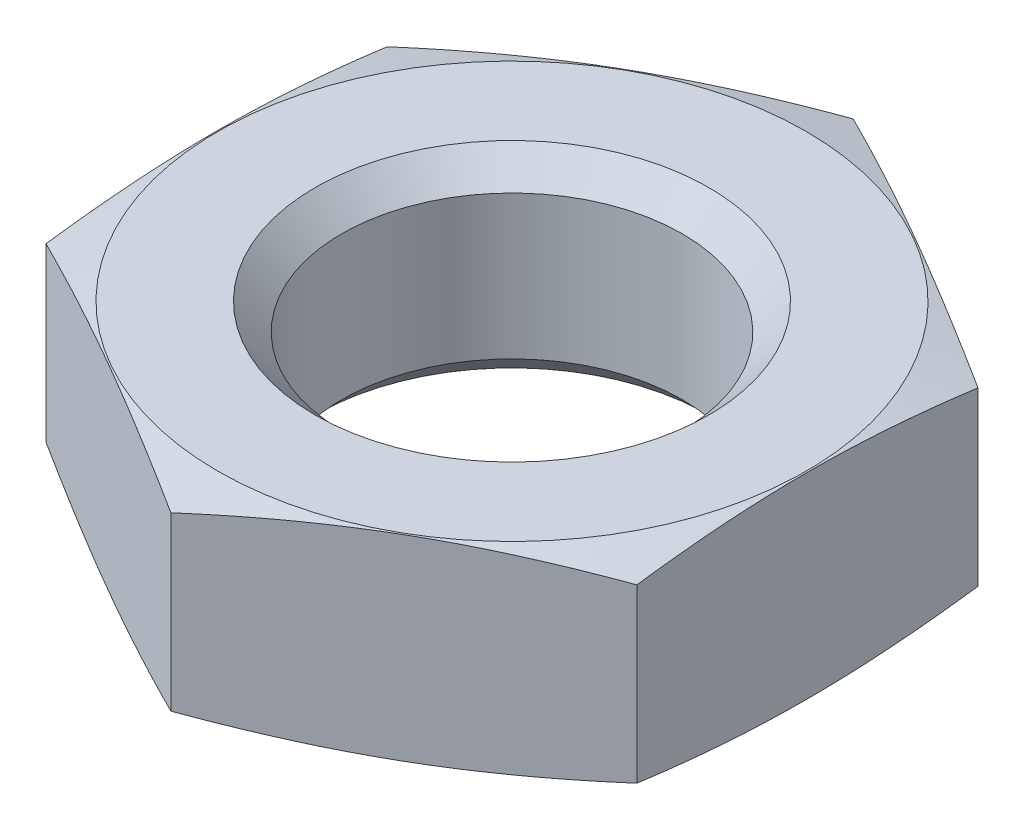
from build123d import *

# Parameters (mm, degrees)
CUT_EXTRUDE1_DEPTH      = 9
CUT_EXTRUDE1_DEPTH_BACK = 9
SKETCH2_W               = 96
SKETCH2_H               = 96


with BuildPart() as part:
    # Sketch1 → Revolve1 (revolve)
    with BuildSketch(Plane.XY):
        Polygon((0, 0), (11.95, 0), (26.87820323, -4), (11.95, -8), (0, -8), align=None)
    revolve(axis=Axis((0, -8, 0), (0, 1, 0)))

    # Sketch2 → Cut-Extrude1 (cut, two sides: drawn at the far end of the back side and taken through both)
    with BuildSketch(Plane(origin=(0, 0, 0), x_dir=(1, 0, 0), z_dir=(0, 1, 0)).offset(-CUT_EXTRUDE1_DEPTH_BACK)):
        Rectangle(SKETCH2_W, SKETCH2_H)
        Polygon((-12, -6.92820323), (0, -13.856406461), (12, -6.92820323), (12, 6.92820323), (0, 13.856406461), (-12, 6.92820323), align=None, mode=Mode.SUBTRACT)
    extrude(amount=CUT_EXTRUDE1_DEPTH + CUT_EXTRUDE1_DEPTH_BACK, mode=Mode.SUBTRACT)

    # Sketch3 → Cut-Revolve1 (revolve, cut)
    with BuildSketch(Plane.XY):
        Polygon((0, 0), (8, 0), (6.9175, -1.0825), (6.9175, -6.9175), (8, -8), (0, -8), align=None)
    revolve(axis=Axis((0, -8, 0), (0, 1, 0)), mode=Mode.SUBTRACT)


solid = part.part
